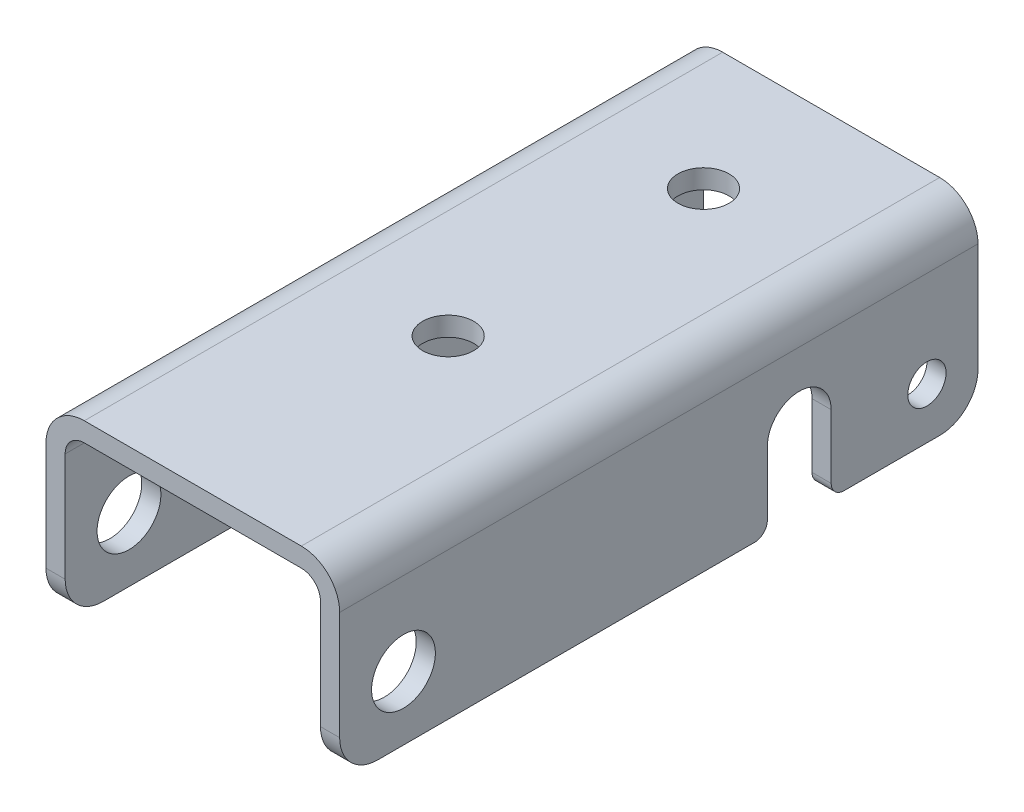
from build123d import *

# Parameters (mm, degrees)
BOSS_EXTRUDE1_DEPTH = 25
FILLET1_R           = 3
CUT_EXTRUDE1_DEPTH  = 24
FILLET2_R           = 1
SKETCH3_R           = 2.5
CUT_EXTRUDE2_DEPTH  = 24
SKETCH4_R           = 1.5
CUT_EXTRUDE3_DEPTH  = 24
SKETCH5_R           = 2
CUT_EXTRUDE4_DEPTH  = 50


with BuildPart() as part:
    # Sketch1 → Boss-Extrude1 (new body, symmetric)
    with BuildSketch(Plane.XY):
        with BuildLine():
            Line((11.5, 0), (11.5, 11.5))
            ThreePointArc((11.5, 11.5), (10.621320344, 13.621320344), (8.5, 14.5))
            Line((8.5, 14.5), (-8.5, 14.5))
            ThreePointArc((-8.5, 14.5), (-10.621320344, 13.621320344), (-11.5, 11.5))
            Line((-11.5, 11.5), (-11.5, 0))
            Line((-11.5, 0), (-10, 0))
            Line((-10, 0), (-10, 11.5))
            ThreePointArc((-10, 11.5), (-9.560660172, 12.560660172), (-8.5, 13))
            Line((-8.5, 13), (8.5, 13))
            ThreePointArc((8.5, 13), (9.560660172, 12.560660172), (10, 11.5))
            Line((10, 11.5), (10, 0))
            Line((10, 0), (11.5, 0))
        make_face()
    extrude(amount=BOSS_EXTRUDE1_DEPTH, both=True)

    # Fillet1
    fillet1_edges = [part.edges().sort_by_distance(p)[0] for p in [
        (-10.75, 0, -25),
        (10.75, 0, -25),
        (-10.75, 0, 25),
        (10.75, 0, 25),
    ]]
    fillet(fillet1_edges, radius=FILLET1_R)

    # Sketch2 → Cut-Extrude1 (cut, through all)
    with BuildSketch(Plane(origin=(11.5, 0, 0), x_dir=(0, 0, -1), z_dir=(1, 0, 0))):
        with BuildLine():
            Line((8.5, 0), (8.5, 6))
            ThreePointArc((8.5, 6), (11, 8.5), (13.5, 6))
            Line((13.5, 6), (13.5, 0))
            Line((13.5, 0), (8.5, 0))
        make_face()
    extrude(amount=-CUT_EXTRUDE1_DEPTH, mode=Mode.SUBTRACT)

    # Fillet2
    fillet2_edges = [part.edges().sort_by_distance(p)[0] for p in [
        (-10.75, 0, -13.5),
        (10.75, 0, -13.5),
        (-10.75, 0, -8.5),
        (10.75, 0, -8.5),
    ]]
    fillet(fillet2_edges, radius=FILLET2_R)

    # Sketch3 → Cut-Extrude2 (cut, through all)
    with BuildSketch(Plane(origin=(11.5, 0, 0), x_dir=(0, 0, -1), z_dir=(1, 0, 0))):
        with Locations((-20, 5)):
            Circle(SKETCH3_R)
    extrude(amount=-CUT_EXTRUDE2_DEPTH, mode=Mode.SUBTRACT)

    # Sketch4 → Cut-Extrude3 (cut, through all)
    with BuildSketch(Plane(origin=(11.5, 0, 0), x_dir=(0, 0, -1), z_dir=(1, 0, 0))):
        with Locations((21, 4)):
            Circle(SKETCH4_R)
    extrude(amount=-CUT_EXTRUDE3_DEPTH, mode=Mode.SUBTRACT)

    # Sketch5 → Cut-Extrude4 (cut)
    with BuildSketch(Plane(origin=(0, 14.5, 0), x_dir=(1, 0, 0), z_dir=(0, 1, 0))):
        with Locations((0, 15)):
            Circle(SKETCH5_R)
        with Locations((0, -5)):
            Circle(SKETCH5_R)
    extrude(amount=-CUT_EXTRUDE4_DEPTH, mode=Mode.SUBTRACT)


solid = part.part
